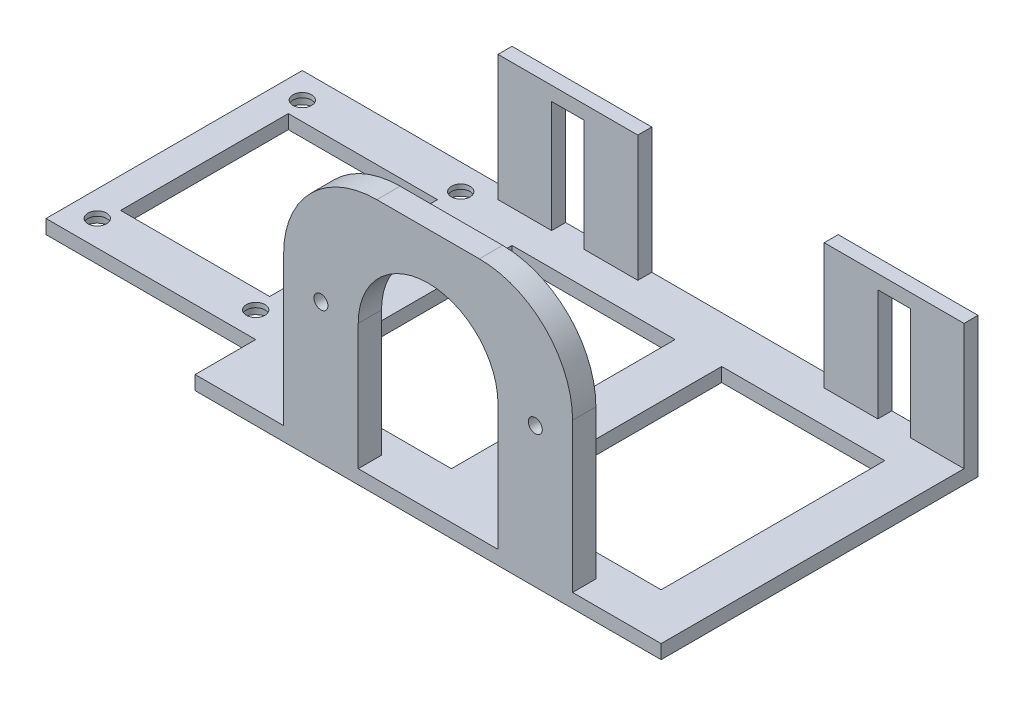
from build123d import *

# Parameters (mm, degrees)
SKETCH_1_W           = 100
SKETCH_1_H           = 68
EXTRUDE_1_DEPTH      = 3
SKETCH_2_W           = 100
SKETCH_2_H           = 3
EXTRUDE_2_DEPTH      = 27
SKETCH_3_W           = 7
SKETCH_3_H           = 24
CUT_EXTRUDE_2_DEPTH  = 27
SKETCH_4_W           = 62
SKETCH_4_H           = 5
EXTRUDE_3_DEPTH      = 52
SKETCH_5_R           = 1.5
CUT_EXTRUDE_4_DEPTH  = 5
SKETCH_7_W           = 35
SKETCH_7_H           = 48
CUT_EXTRUDE_5_DEPTH  = 3
SKETCH_11_W          = 55
SKETCH_11_H          = 3
EXTRUDE_5_DEPTH      = 45
SKETCH_13_R          = 2
SKETCH_13_W          = 32
SKETCH_13_H          = 36
CUT_EXTRUDE_8_DEPTH  = 3
SKETCH_14_R          = 3
CUT_EXTRUDE_9_DEPTH  = 2
SKETCH_15_W          = 40
SKETCH_15_H          = 27
CUT_EXTRUDE_10_DEPTH = 3
FILLET_1_R           = 20


with BuildPart() as part:
    # 스케치1 → 보스-돌출1 (new body)
    with BuildSketch(Plane(origin=(0, 0, 0), x_dir=(1, 0, 0), z_dir=(0, 1, 0))):
        Rectangle(SKETCH_1_W, SKETCH_1_H)
    extrude(amount=EXTRUDE_1_DEPTH)

    # 스케치2 → 보스-돌출2 (add)
    with BuildSketch(Plane(origin=(0, 3, 0), x_dir=(1, 0, 0), z_dir=(0, 1, 0))):
        with Locations((0, 32.5)):
            Rectangle(SKETCH_2_W, SKETCH_2_H)
    extrude(amount=EXTRUDE_2_DEPTH)

    # 스케치3 → 컷-돌출2 (cut)
    with BuildSketch(Plane.XY.offset(-31)):
        with Locations((-35, 15)):
            Rectangle(SKETCH_3_W, SKETCH_3_H)
        with Locations((35, 15)):
            Rectangle(SKETCH_3_W, SKETCH_3_H)
    extrude(amount=-CUT_EXTRUDE_2_DEPTH, mode=Mode.SUBTRACT)

    # 스케치4 → 보스-돌출3 (add)
    with BuildSketch(Plane(origin=(0, 3, 0), x_dir=(1, 0, 0), z_dir=(0, 1, 0))):
        with Locations((0, -31.5)):
            Rectangle(SKETCH_4_W, SKETCH_4_H)
    extrude(amount=EXTRUDE_3_DEPTH)

    # 스케치5 → 컷-돌출4 (cut)
    with BuildSketch(Plane.XY.offset(34)):
        with Locations((-23, 30)):
            Circle(SKETCH_5_R)
        with Locations((23, 30)):
            Circle(SKETCH_5_R)
        with BuildLine():
            Line((-15, 30), (-15, 3))
            Line((-15, 3), (15, 3))
            Line((15, 3), (15, 30))
            ThreePointArc((15, 30), (0, 45), (-15, 30))
        make_face()
    extrude(amount=-CUT_EXTRUDE_4_DEPTH, mode=Mode.SUBTRACT)

    # 스케치7 → 컷-돌출5 (cut)
    with BuildSketch(Plane.XZ):
        with Locations((22.5, 0)):
            Rectangle(SKETCH_7_W, SKETCH_7_H)
        with Locations((-22.5, 0)):
            Rectangle(SKETCH_7_W, SKETCH_7_H)
    extrude(amount=-CUT_EXTRUDE_5_DEPTH, mode=Mode.SUBTRACT)

    # 스케치11 → 보스-돌출5 (add)
    with BuildSketch(Plane.ZY.offset(50)):
        with Locations((-6.5, 1.5)):
            Rectangle(SKETCH_11_W, SKETCH_11_H)
    extrude(amount=EXTRUDE_5_DEPTH)

    # 스케치13 → 컷-돌출8 (cut)
    with BuildSketch(Plane(origin=(0, 3, 0), x_dir=(1, 0, 0), z_dir=(0, 1, 0))):
        with Locations((-55.5, -15.5)):
            Circle(SKETCH_13_R)
        with Locations((-89.5, -15.5)):
            Circle(SKETCH_13_R)
        with Locations((-89.5, 28.5)):
            Circle(SKETCH_13_R)
        with Locations((-55.5, 28.5)):
            Circle(SKETCH_13_R)
        with Locations((-72.5, 6.5)):
            Rectangle(SKETCH_13_W, SKETCH_13_H)
    extrude(amount=-CUT_EXTRUDE_8_DEPTH, mode=Mode.SUBTRACT)

    # 스케치14 → 컷-돌출9 (cut)
    with BuildSketch(Plane.XZ):
        with Locations((-89.5, 15.5)):
            Circle(SKETCH_14_R)
        with Locations((-89.5, -28.5)):
            Circle(SKETCH_14_R)
        with Locations((-55.5, -28.5)):
            Circle(SKETCH_14_R)
        with Locations((-55.5, 15.5)):
            Circle(SKETCH_14_R)
    extrude(amount=-CUT_EXTRUDE_9_DEPTH, mode=Mode.SUBTRACT)

    # 스케치15 → 컷-돌출10 (cut)
    with BuildSketch(Plane(origin=(0, 0, -34), x_dir=(-1, 0, 0), z_dir=(0, 0, -1))):
        with Locations((0, 16.5)):
            Rectangle(SKETCH_15_W, SKETCH_15_H)
    extrude(amount=-CUT_EXTRUDE_10_DEPTH, mode=Mode.SUBTRACT)

    # 필렛1
    fillet_1_edges = [part.edges().sort_by_distance(p)[0] for p in [
        (31, 55, 31.5),
        (-31, 55, 31.5),
    ]]
    fillet(fillet_1_edges, radius=FILLET_1_R)


solid = part.part
